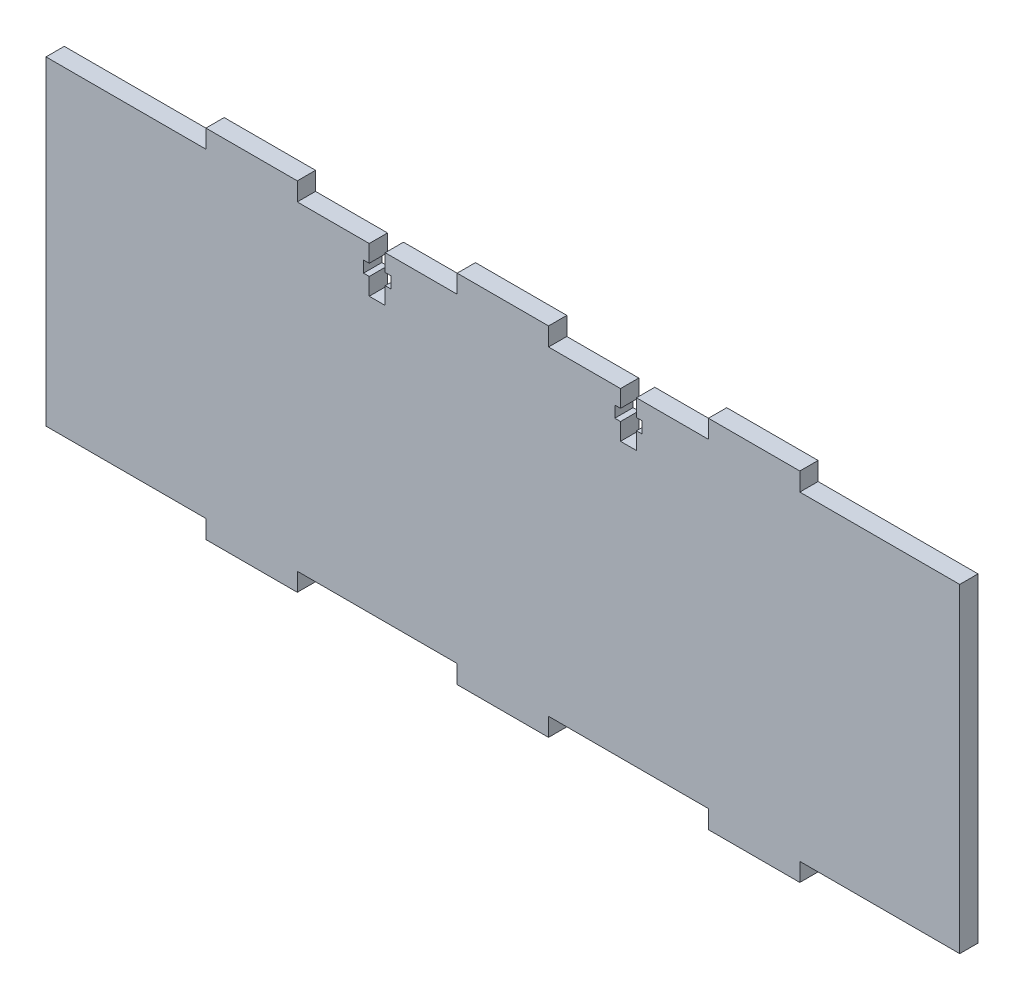
from build123d import *

# Parameters (mm, degrees)
SKETCH1_W           = 200
SKETCH1_H           = 78
BOSS_EXTRUDE1_DEPTH = 4
SKETCH2_W           = 35
SKETCH2_H           = 4
CUT_EXTRUDE1_DEPTH  = 4
CUT_EXTRUDE2_DEPTH  = 4


with BuildPart() as part:
    # Sketch1 → Boss-Extrude1 (new body)
    with BuildSketch(Plane.XY):
        with Locations((-100, 39)):
            Rectangle(SKETCH1_W, SKETCH1_H)
    extrude(amount=BOSS_EXTRUDE1_DEPTH)

    # Sketch2 → Cut-Extrude1 (cut)
    with BuildSketch(Plane.XY.offset(4)):
        with Locations((-182.5, 76)):
            Rectangle(SKETCH2_W, SKETCH2_H)
        with Locations((-127.5, 76)):
            Rectangle(SKETCH2_W, SKETCH2_H)
        with Locations((-72.5, 76)):
            Rectangle(SKETCH2_W, SKETCH2_H)
        with Locations((-17.5, 76)):
            Rectangle(SKETCH2_W, SKETCH2_H)
        with Locations((-182.5, 2)):
            Rectangle(SKETCH2_W, SKETCH2_H)
        with Locations((-127.5, 2)):
            Rectangle(SKETCH2_W, SKETCH2_H)
        with Locations((-72.5, 2)):
            Rectangle(SKETCH2_W, SKETCH2_H)
        with Locations((-17.5, 2)):
            Rectangle(SKETCH2_W, SKETCH2_H)
    extrude(amount=-CUT_EXTRUDE1_DEPTH, mode=Mode.SUBTRACT)

    # Sketch4 → Cut-Extrude2 (cut)
    with BuildSketch(Plane.XY.offset(4)):
        Polygon((-125.75, 74), (-129.25, 74), (-129.25, 70.25), (-130.5, 70.25), (-130.5, 67.75), (-129.25, 67.75), (-129.25, 64), (-125.75, 64), (-125.75, 67.75), (-124.5, 67.75), (-124.5, 70.25), (-125.75, 70.25), align=None)
        Polygon((-70.75, 67.75), (-69.5, 67.75), (-69.5, 70.25), (-70.75, 70.25), (-70.75, 74), (-74.25, 74), (-74.25, 70.25), (-75.5, 70.25), (-75.5, 67.75), (-74.25, 67.75), (-74.25, 64), (-70.75, 64), align=None)
    extrude(amount=-CUT_EXTRUDE2_DEPTH, mode=Mode.SUBTRACT)


solid = part.part
